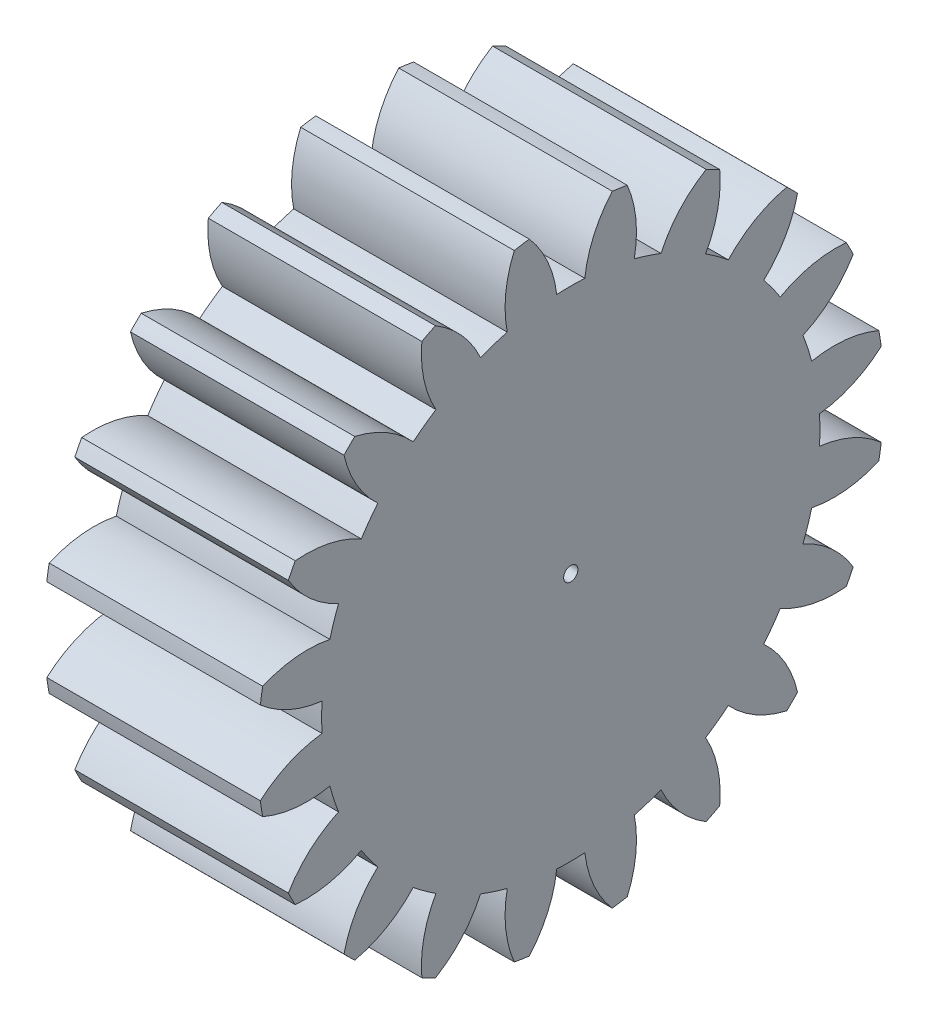
from build123d import *

# Parameters (mm, degrees)
BASPROSKE_W     = 15
BASPROSKE_H     = 22
TOOTHCUT_DEPTH  = 35.539832078
TEETHCUTS_COUNT = 20
TEETHCUTS_ANGLE = 342
BORSKE_R        = 0.5
BORE_DEPTH      = 50.0000508


with BuildPart() as part:
    # BasProSke → Base-Revolve (revolve)
    with BuildSketch(Plane(origin=(0, 0, 0), x_dir=(1, 0, 0), z_dir=(0, 1, 0)), mode=Mode.PRIVATE) as base_revolve_sk:
        with Locations((7.5, 11)):
            Rectangle(BASPROSKE_W, BASPROSKE_H)
    revolve(base_revolve_sk.sketch.rotate(Axis((-10, 0, 0), (1, 0, 0)), 180), axis=Axis((-10, 0, 0), (1, 0, 0)))

    # TooCutSke → ToothCut (cut, through all)
    with BuildSketch(Plane(origin=(0, 0, 0), x_dir=(0, 0, -1), z_dir=(1, 0, 0))):
        with BuildLine():
            ThreePointArc((0.986171591, 17.471189616), (0, 17.499), (-0.986171591, 17.471189616))
            ThreePointArc((-0.986171591, 17.471189616), (-1.626916196, 19.798789858), (-2.932850173, 21.829260982))
            ThreePointArc((-2.932850173, 21.829260982), (0, 22.0254), (2.932850173, 21.829260982))
            ThreePointArc((2.932850173, 21.829260982), (1.626916196, 19.798789858), (0.986171591, 17.471189616))
        make_face()
    toothcut = extrude(amount=TOOTHCUT_DEPTH, mode=Mode.SUBTRACT)

    # TeethCuts: ToothCut ×20 about axis
    teethcuts_axis = Axis((-10, 0, 0), (1, 0, 0))
    for i in range(1, TEETHCUTS_COUNT):
        add(toothcut.rotate(teethcuts_axis, i * TEETHCUTS_ANGLE / (TEETHCUTS_COUNT - 1)), mode=Mode.SUBTRACT)

    # BorSke → Bore (cut, symmetric)
    with BuildSketch(Plane(origin=(0, 0, 0), x_dir=(0, 0, -1), z_dir=(1, 0, 0))):
        with Locations(Location((0, 0, 0), (0, 0, 180))):
            Circle(BORSKE_R)
    extrude(amount=BORE_DEPTH, both=True, mode=Mode.SUBTRACT)


solid = part.part
